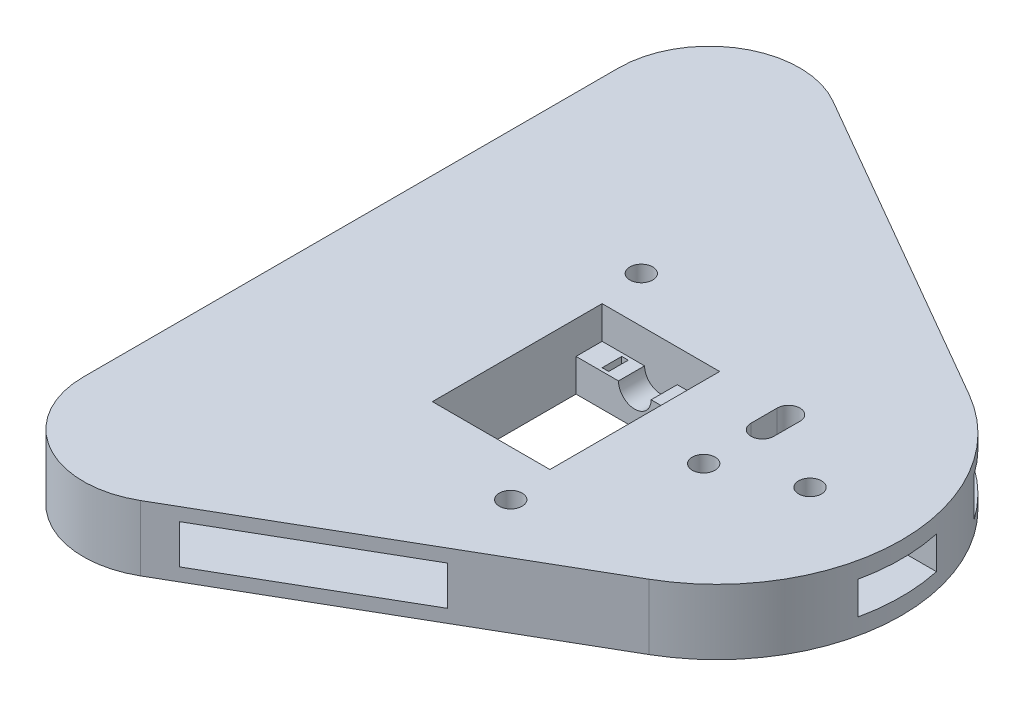
from build123d import *

# Parameters (mm, degrees)
BOSS_EXTRUDE1_DEPTH              = 5
MAINSKETCH_19_W                  = 18
MAINSKETCH_19_H                  = 18
BOSS_EXTRUDE2_DEPTH              = 5
CUT_EXTRUDE1_START               = 9
SKETCH1_R                        = 2.5
CUT_EXTRUDE1_DEPTH               = 13
SKETCH2_W                        = 1
SKETCH2_H                        = 3
CUT_EXTRUDE2_DEPTH               = 6
MIRROR2_COPY_1_SKETCH_W          = 1
MIRROR2_COPY_1_SKETCH_H          = 3
MIRROR2_COPY_1_DEPTH             = 6
HOLESKETCH_R                     = 4
CUT_EXTRUDE3_DEPTH               = 6
CUT_EXTRUDE3_DEPTH_BACK          = 2
CUT_EXTRUDE4_DEPTH               = 3
SCHNITT_LINEAR_AUSTRAGEN2_DEPTH  = 2.5
SKIZZE3_R                        = 1.75
SCHNITT_LINEAR_AUSTRAGEN3_DEPTH  = 11
SKIZZE4_R                        = 1.75
SCHNITT_LINEAR_AUSTRAGEN4_DEPTH  = 1.5
SKIZZE6_R                        = 1.75
SCHNITT_LINEAR_AUSTRAGEN6_DEPTH  = 11
SKIZZE7_R                        = 1.75
SCHNITT_LINEAR_AUSTRAGEN7_DEPTH  = 2.5
SKIZZE8_R                        = 1.75
SCHNITT_LINEAR_AUSTRAGEN8_DEPTH  = 11
SKIZZE9_R                        = 1.75
SCHNITT_LINEAR_AUSTRAGEN10_DEPTH = 2.5


with BuildPart() as part:
    # mainSketch → Boss-Extrude1 (new body)
    with BuildSketch(Plane(origin=(0, 0, 0), x_dir=(1, 0, 0), z_dir=(0, 1, 0))):
        with BuildLine():
            ThreePointArc((-18.215390309, 53), (-32.07179677, 53), (-39, 41))
            Line((-39, 41), (-39, -41))
            ThreePointArc((-39, -41), (-32.07179677, -53), (-18.215390309, -53))
            Line((-18.215390309, -53), (31.145825623, -24.501288694))
            ThreePointArc((31.145825623, -24.501288694), (45.291651246, 0), (31.145825623, 24.501288694))
            Line((31.145825623, 24.501288694), (-18.215390309, 53))
        make_face()
        Polygon((-9, -13.55), (-9, 4.45), (-9, 8.45), (9, 8.45), (9, 4.45), (9, -13.55), (9, -17.55), (-9, -17.55), align=None, mode=Mode.SUBTRACT)
    extrude(amount=BOSS_EXTRUDE1_DEPTH)

    # mainSketch_19 → Boss-Extrude2 (add)
    with BuildSketch(Plane(origin=(0, 0, 0), x_dir=(1, 0, 0), z_dir=(0, 1, 0))):
        with BuildLine():
            ThreePointArc((-18.215390309, 53), (-32.07179677, 53), (-39, 41))
            Line((-39, 41), (-39, -41))
            ThreePointArc((-39, -41), (-32.07179677, -53), (-18.215390309, -53))
            Line((-18.215390309, -53), (31.145825623, -24.501288694))
            ThreePointArc((31.145825623, -24.501288694), (45.291651246, 0), (31.145825623, 24.501288694))
            Line((31.145825623, 24.501288694), (-18.215390309, 53))
        make_face()
        with Locations((0, -4.55)):
            Rectangle(MAINSKETCH_19_W, MAINSKETCH_19_H, mode=Mode.SUBTRACT)
    extrude(amount=-BOSS_EXTRUDE2_DEPTH)

    # Sketch1 → Cut-Extrude1 (cut, symmetric)
    with BuildSketch(Plane(origin=(0, 0, 13.55), x_dir=(-1, 0, 0), z_dir=(0, 0, -1)).offset(CUT_EXTRUDE1_START)):
        Circle(SKETCH1_R)
    extrude(amount=CUT_EXTRUDE1_DEPTH, both=True, mode=Mode.SUBTRACT)

    # Sketch2 → Cut-Extrude2 (cut, through all)
    with BuildSketch(Plane(origin=(0, 0, 0), x_dir=(1, 0, 0), z_dir=(0, 1, 0))):
        with Locations((5, -15.55)):
            Rectangle(SKETCH2_W, SKETCH2_H)
    cut_extrude2 = extrude(amount=-CUT_EXTRUDE2_DEPTH, mode=Mode.SUBTRACT)

    # Mirror1: Cut-Extrude2 across plane
    add(cut_extrude2.mirror(Plane(origin=(0, 0, 0), x_dir=(0, 0, 1), z_dir=(1, 0, 0))), mode=Mode.SUBTRACT)

    # Mirror2: Cut-Extrude2 across plane
    add(cut_extrude2.mirror(Plane(origin=(0, 0, 4.55), x_dir=(1, 0, 0), z_dir=(0, 0, -1))), mode=Mode.SUBTRACT)

    # Mirror2 copy 1 sketch → Mirror2 copy 1 (cut, through all)
    with BuildSketch(Plane(origin=(0, 0, 9.1), x_dir=(-1, 0, 0), z_dir=(0, 1, 0))):
        with Locations((5, -15.55)):
            Rectangle(MIRROR2_COPY_1_SKETCH_W, MIRROR2_COPY_1_SKETCH_H)
    extrude(amount=-MIRROR2_COPY_1_DEPTH, mode=Mode.SUBTRACT)

    # holeSketch → Cut-Extrude3 (cut, two sides)
    with BuildSketch(Plane.XZ) as cut_extrude3_sk:
        with Locations(Location((29.25, -15.5, 0), (0, 0, 270))):  # turned: the seam where the file's is
            Circle(HOLESKETCH_R)
        with Locations(Location((-2.443479184, 27.5, 0), (0, 0, 270))):  # turned: the seam where the file's is
            Circle(HOLESKETCH_R)
        with Locations(Location((-29.6, -18.5, 0), (0, 0, 270))):  # turned: the seam where the file's is
            Circle(HOLESKETCH_R)
    extrude(amount=CUT_EXTRUDE3_DEPTH, mode=Mode.SUBTRACT)
    extrude(cut_extrude3_sk.sketch, amount=-CUT_EXTRUDE3_DEPTH_BACK, mode=Mode.SUBTRACT)

    # Sketch3 → Cut-Extrude4 (cut, symmetric)
    with BuildSketch(Plane(origin=(0, 0, 0), x_dir=(1, 0, 0), z_dir=(0, 1, 0))):
        with BuildLine():
            Line((-29.6, 26.5), (-39, 26.5))
            Line((-39, 26.5), (-39.6, 26.5))
            Line((-39.6, 26.5), (-39.6, -6.5))
            Line((-39.6, -6.5), (-37.6, -6.5))
            Line((-37.6, -6.5), (-21.6, -6.5))
            Line((-21.6, -6.5), (-21.6, 18.5))
            ThreePointArc((-21.6, 18.5), (-23.943145751, 24.156854249), (-29.6, 26.5))
        make_face()
        with BuildLine():
            Line((4.484724046, -23.5), (11.583570163, -35.79556215))
            Line((11.583570163, -35.79556215), (-8.960116539, -56.33889432))
            Line((-8.960116539, -56.33889432), (-14.464495813, -50.834420053))
            Line((-14.464495813, -50.834420053), (-25.778106688, -39.520613931))
            Line((-25.778106688, -39.520613931), (-8.100284622, -21.843096939))
            ThreePointArc((-8.100284622, -21.843096939), (-1.399235427, -19.568445614), (4.484724046, -23.5))
        make_face()
        with BuildLine():
            Line((40.858217841, 16.978745932), (35.413092194, 10.399382918))
            ThreePointArc((35.413092194, 10.399382918), (30.548118213, 7.606021972), (25.044818187, 8.694381298))
            Line((25.044818187, 8.694381298), (3.777259743, 21.835574464))
            Line((3.777259743, 21.835574464), (12.187623369, 35.446811868))
            Line((12.187623369, 35.446811868), (14.338041609, 38.927024434))
            Line((14.338041609, 38.927024434), (40.858217841, 16.978745932))
        make_face()
    extrude(amount=CUT_EXTRUDE4_DEPTH, both=True, mode=Mode.SUBTRACT)

    # Skizze2 → Schnitt-Linear austragen2 (cut, symmetric)
    with BuildSketch(Plane(origin=(0, 0, 0), x_dir=(1, 0, 0), z_dir=(0, 1, 0))):
        with BuildLine():
            ThreePointArc((45.291651246, 0), (45.130303789, 3.017207151), (44.648101747, 6))
            Line((44.648101747, 6), (25.291651246, 6))
            Line((25.291651246, 6), (25.291651246, -6))
            Line((25.291651246, -6), (44.648101747, -6))
            ThreePointArc((44.648101747, -6), (45.130303789, -3.017207151), (45.291651246, 0))
        make_face()
    extrude(amount=SCHNITT_LINEAR_AUSTRAGEN2_DEPTH, both=True, mode=Mode.SUBTRACT)

    # Skizze3 → Schnitt-Linear austragen3 (cut, through all)
    with BuildSketch(Plane(origin=(0, 5, 0), x_dir=(1, 0, 0), z_dir=(0, 1, 0))):
        with Locations(Location((31.291651246, 0, 0), (0, 0, 270))):  # turned: the seam where the file's is
            Circle(SKIZZE3_R)
    extrude(amount=-SCHNITT_LINEAR_AUSTRAGEN3_DEPTH, mode=Mode.SUBTRACT)

    # Skizze4 → Schnitt-Linear austragen4 (cut)
    with BuildSketch(Plane.XZ.offset(5)):
        Polygon((34.291651246, 1.732050808), (31.291651246, 3.464101615), (28.291651246, 1.732050808), (28.291651246, -1.732050808), (31.291651246, -3.464101615), (34.291651246, -1.732050808), align=None)
        with Locations(Location((31.291651246, 0, 0), (0, 0, 90))):  # turned: the seam where the file's is
            Circle(SKIZZE4_R, mode=Mode.SUBTRACT)
    extrude(amount=-SCHNITT_LINEAR_AUSTRAGEN4_DEPTH, mode=Mode.SUBTRACT)

    # Skizze6 → Schnitt-Linear austragen6 (cut, through all)
    with BuildSketch(Plane(origin=(0, 5, 0), x_dir=(1, 0, 0), z_dir=(0, 1, 0))):
        with Locations(Location((20, -5, 0), (0, 0, 270))):  # turned: the seam where the file's is
            Circle(SKIZZE6_R)
        with BuildLine():
            Line((18.25, 4), (18.25, 8))
            ThreePointArc((18.25, 8), (20, 9.75), (21.75, 8))
            Line((21.75, 8), (21.75, 4))
            ThreePointArc((21.75, 4), (20, 2.25), (18.25, 4))
        make_face()
    extrude(amount=-SCHNITT_LINEAR_AUSTRAGEN6_DEPTH, mode=Mode.SUBTRACT)

    # Skizze7 → Schnitt-Linear austragen7 (cut)
    with BuildSketch(Plane.XZ.offset(5)):
        Polygon((23, 3.267949192), (23, 6.732050808), (20, 8.464101615), (17, 6.732050808), (17, 3.267949192), (20, 1.535898385), align=None)
        with Locations(Location((20, 5, 0), (0, 0, 90))):  # turned: the seam where the file's is
            Circle(SKIZZE7_R, mode=Mode.SUBTRACT)
        with BuildLine():
            Line((17, -2.267949192), (17, -5.732050808))
            Line((17, -5.732050808), (17.464101615, -6))
            Line((17.464101615, -6), (18.25, -5.546261356))
            Line((18.25, -5.546261356), (18.25, -4))
            ThreePointArc((18.25, -4), (20, -2.25), (21.75, -4))
            Line((21.75, -4), (21.75, -5.546261356))
            Line((21.75, -5.546261356), (22.535898385, -6))
            Line((22.535898385, -6), (23, -5.732050808))
            Line((23, -5.732050808), (23, -2.267949192))
            Line((23, -2.267949192), (20, -0.535898385))
            Line((20, -0.535898385), (17, -2.267949192))
        make_face()
        with BuildLine():
            Line((17.464101615, -6), (17, -6.267949192))
            Line((17, -6.267949192), (17, -9.732050808))
            Line((17, -9.732050808), (20, -11.464101615))
            Line((20, -11.464101615), (23, -9.732050808))
            Line((23, -9.732050808), (23, -6.267949192))
            Line((23, -6.267949192), (22.535898385, -6))
            Line((22.535898385, -6), (21.75, -6.453738644))
            Line((21.75, -6.453738644), (21.75, -8))
            ThreePointArc((21.75, -8), (20, -9.75), (18.25, -8))
            Line((18.25, -8), (18.25, -6.453738644))
            Line((18.25, -6.453738644), (17.464101615, -6))
        make_face()
        Polygon((17.464101615, -6), (17, -5.732050808), (17, -6.267949192), align=None)
        Polygon((18.25, -5.546261356), (17.464101615, -6), (18.25, -6.453738644), align=None)
        Polygon((21.75, -5.546261356), (21.75, -6.453738644), (22.535898385, -6), align=None)
        Polygon((23, -6.267949192), (23, -5.732050808), (22.535898385, -6), align=None)
    extrude(amount=-SCHNITT_LINEAR_AUSTRAGEN7_DEPTH, mode=Mode.SUBTRACT)

    # Skizze8 → Schnitt-Linear austragen8 (cut, through all)
    with BuildSketch(Plane(origin=(0, 5, 0), x_dir=(1, 0, 0), z_dir=(0, 1, 0))):
        with Locations(Location((-10, 15.45, 0), (0, 0, 270))):  # turned: the seam where the file's is
            Circle(SKIZZE8_R)
        with Locations(Location((10, -24.55, 0), (0, 0, 270))):  # turned: the seam where the file's is
            Circle(SKIZZE8_R)
    extrude(amount=-SCHNITT_LINEAR_AUSTRAGEN8_DEPTH, mode=Mode.SUBTRACT)

    # Skizze9 → Schnitt-Linear austragen10 (cut)
    with BuildSketch(Plane(origin=(0, -5, 0), x_dir=(1, 0, 0), z_dir=(0, 1, 0))):
        Polygon((-10, 18.914101615), (-13, 17.182050808), (-13, 13.717949192), (-10, 11.985898385), (-7, 13.717949192), (-7, 17.182050808), align=None)
        with Locations(Location((-10, 15.45, 0), (0, 0, 270))):  # turned: the seam where the file's is
            Circle(SKIZZE9_R, mode=Mode.SUBTRACT)
        Polygon((13, -26.282050808), (13, -22.817949192), (10, -21.085898385), (7, -22.817949192), (7, -26.282050808), (10, -28.014101615), align=None)
        with Locations(Location((10, -24.55, 0), (0, 0, 270))):  # turned: the seam where the file's is
            Circle(SKIZZE9_R, mode=Mode.SUBTRACT)
    extrude(amount=SCHNITT_LINEAR_AUSTRAGEN10_DEPTH, mode=Mode.SUBTRACT)


solid = part.part
